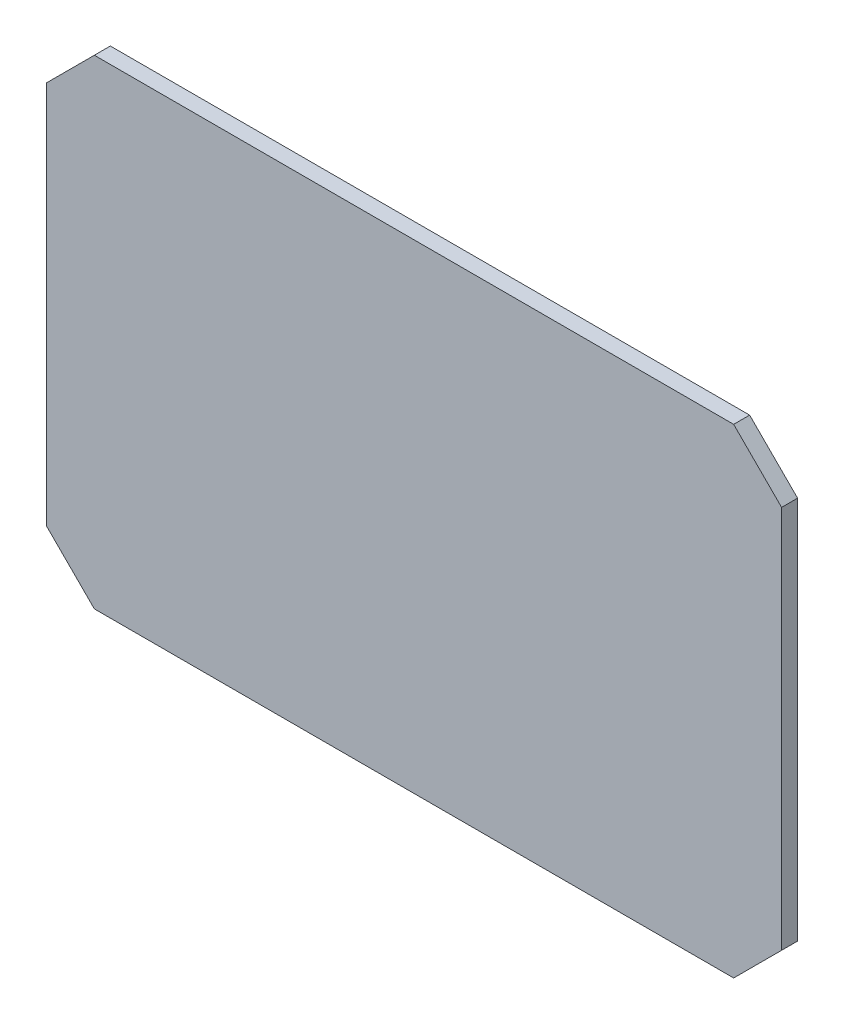
from build123d import *

# Parameters (mm, degrees)
BOSS_EXTRUDE1_DEPTH = 10


with BuildPart() as part:
    # Sketch2 → Boss-Extrude1 (new body)
    with BuildSketch(Plane.XY):
        Polygon((-230, 120), (-200, 150), (200, 150), (230, 120), (230, -120), (200, -150), (-200, -150), (-230, -120), align=None)
    extrude(amount=BOSS_EXTRUDE1_DEPTH)


solid = part.part
